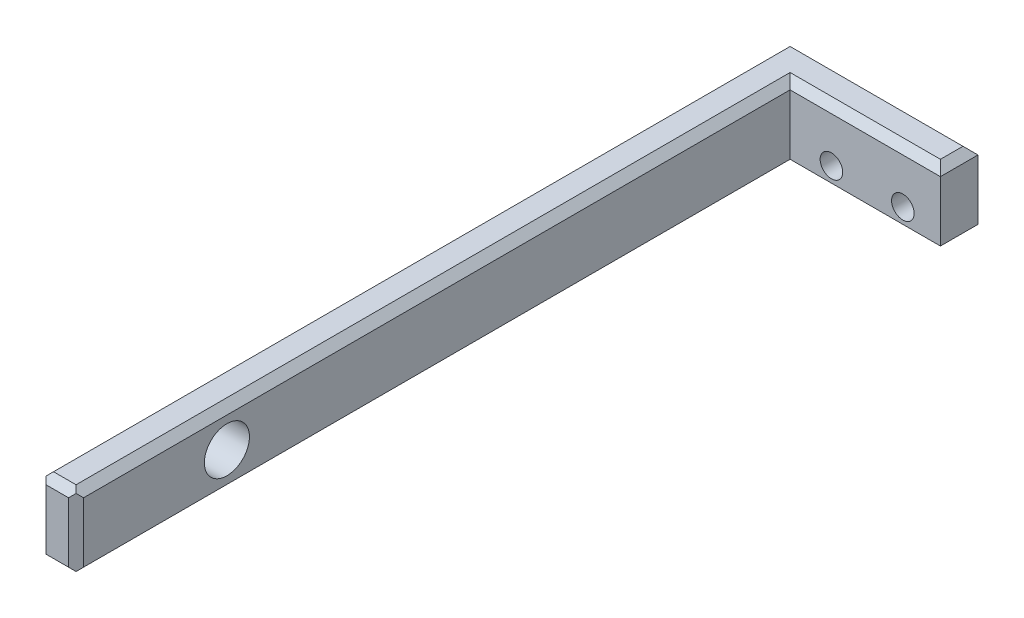
from build123d import *

# Parameters (mm, degrees)
BOSS_EXTRUDE1_DEPTH = 10
SKETCH2_R           = 3
CUT_EXTRUDE1_DEPTH  = 10
SKETCH3_R           = 1.5
CUT_EXTRUDE2_DEPTH  = 20
CHAMFER1_SIZE       = 1
CHAMFER2_SIZE       = 1
CHAMFER3_SIZE       = 1
CHAMFER4_SIZE       = 1


with BuildPart() as part:
    # Sketch1 → Boss-Extrude1 (new body)
    with BuildSketch(Plane(origin=(0, 0, 0), x_dir=(1, 0, 0), z_dir=(0, 1, 0))):
        Polygon((0, 0), (0, 100), (25, 100), (25, 95), (5, 95), (5, 0), align=None)
    extrude(amount=BOSS_EXTRUDE1_DEPTH)

    # Sketch2 → Cut-Extrude1 (cut)
    with BuildSketch(Plane(origin=(0, 0, 0), x_dir=(0, 0, -1), z_dir=(1, 0, 0))):
        with Locations((20.069491085, 5)):
            Circle(SKETCH2_R)
    extrude(amount=CUT_EXTRUDE1_DEPTH, mode=Mode.SUBTRACT)

    # Sketch3 → Cut-Extrude2 (cut)
    with BuildSketch(Plane(origin=(0, 0, -100), x_dir=(-1, 0, 0), z_dir=(0, 0, -1))):
        with Locations((-20, 3)):
            Circle(SKETCH3_R)
        with Locations((-10.5, 3)):
            Circle(SKETCH3_R)
    extrude(amount=-CUT_EXTRUDE2_DEPTH, mode=Mode.SUBTRACT)

    # Chamfer1
    chamfer1_edges = [part.edges().sort_by_distance(p)[0] for p in [
        (15, 10, -95),
        (25, 10, -97.5),
        (12.5, 10, -100),
        (0, 10, -50),
        (2.5, 10, 0),
        (5, 10, -47.5),
    ]]
    chamfer(chamfer1_edges, length=CHAMFER1_SIZE)

    # Chamfer2
    chamfer2_edges = [part.edges().sort_by_distance(p)[0] for p in [
        (0, 0, -50),
        (12.5, 0, -100),
        (25, 0, -97.5),
        (15, 0, -95),
        (5, 0, -47.5),
        (2.5, 0, 0),
    ]]
    chamfer(chamfer2_edges, length=CHAMFER2_SIZE)

    # Chamfer3
    chamfer3_edges = [part.edges().sort_by_distance(p)[0] for p in [
        (0, 5, -100),
    ]]
    chamfer(chamfer3_edges, length=CHAMFER3_SIZE)

    # Chamfer4
    chamfer4_edges = [part.edges().sort_by_distance(p)[0] for p in [
        (0, 5, 0),
        (5, 5, 0),
    ]]
    chamfer(chamfer4_edges, length=CHAMFER4_SIZE)


solid = part.part
